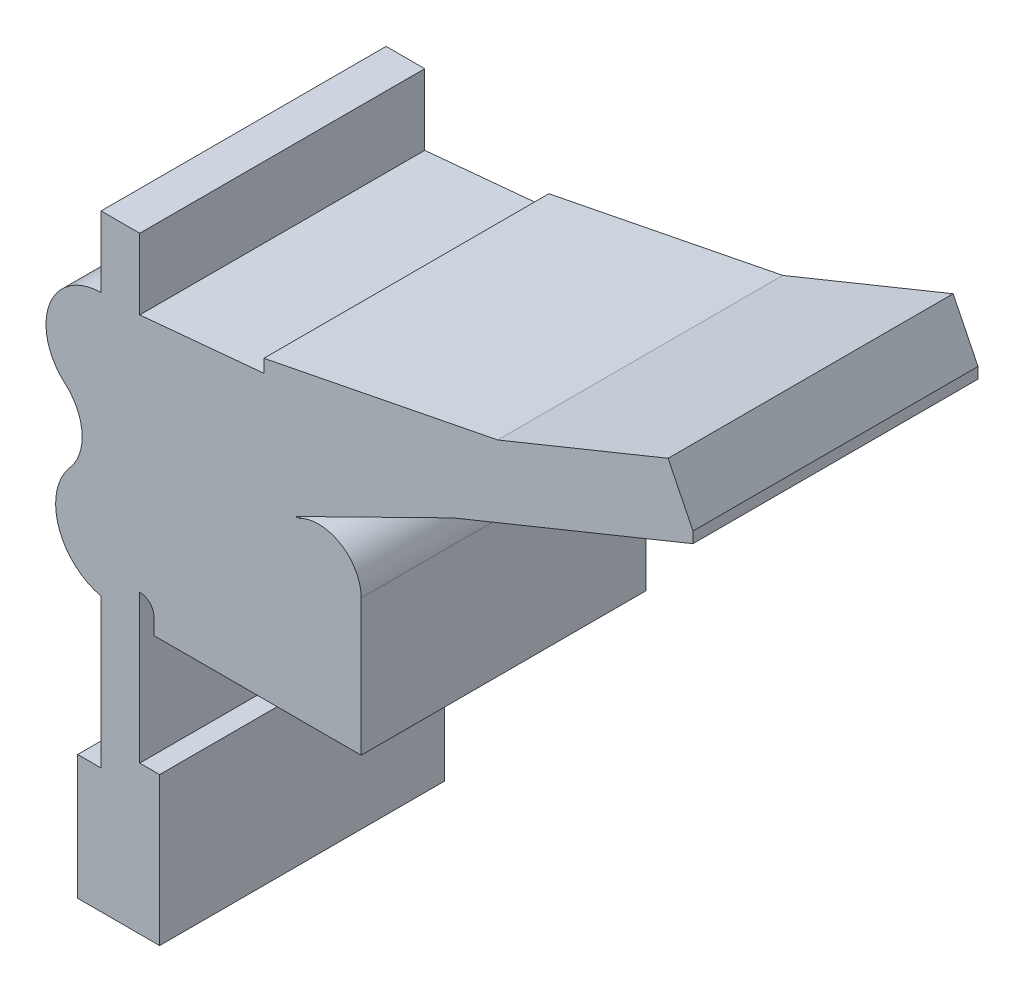
from build123d import *

# Parameters (mm, degrees)
BOSS_EXTRUDE1_DEPTH = 59


with BuildPart() as part:
    # Sketch1 → Boss-Extrude1 (new body)
    with BuildSketch(Plane.XY):
        with BuildLine():
            Line((141.836213574, 162.11895664), (136.686788287, 172.578726755))
            Line((136.686788287, 172.578726755), (101.422420471, 158.233899169))
            Line((101.422420471, 158.233899169), (53.008627367, 148.670680778))
            Line((53.008627367, 148.670680778), (53.008627367, 145.981025606))
            Line((53.008627367, 145.981025606), (27.307477942, 143.590221008))
            Line((27.307477942, 143.590221008), (27.307477942, 158.233899169))
            Line((27.307477942, 158.233899169), (19.307477942, 158.233899169))
            Line((19.307477942, 158.233899169), (19.307477942, 143.590221008))
            ThreePointArc((19.307477942, 143.590221008), (8.621741422, 136.172049269), (11.836213574, 123.567232502))
            ThreePointArc((11.836213574, 123.567232502), (15.367024557, 116.508815615), (12.8726305, 109.02110078))
            ThreePointArc((12.8726305, 109.02110078), (10.487522097, 97.279293257), (19.307477942, 89.169597523))
            Line((19.307477942, 89.169597523), (19.307477942, 58.363836225))
            Line((19.307477942, 58.363836225), (14.461757095, 58.363836225))
            Line((14.461757095, 58.363836225), (14.461757095, 32.578726755))
            Line((14.461757095, 32.578726755), (31.423101088, 32.578726755))
            Line((31.423101088, 32.578726755), (31.423101088, 63.242577829))
            Line((31.423101088, 63.242577829), (27.307477942, 63.242577829))
            Line((27.307477942, 63.242577829), (27.307477942, 93.887357851))
            ThreePointArc((27.307477942, 93.887357851), (29.389559507, 93.024931429), (30.251985929, 90.942849864))
            Line((30.251985929, 90.942849864), (30.251985929, 87.578726755))
            Line((30.251985929, 87.578726755), (73.151157521, 87.578726755))
            Line((73.151157521, 87.578726755), (73.151157521, 91.578726755))
            Line((73.151157521, 91.578726755), (73.151157521, 115.775958178))
            ThreePointArc((73.151157521, 115.775958178), (68.856721822, 123.355383827), (60.147818832, 123.567232502))
            Line((60.147818832, 123.567232502), (59.530992057, 123.567232502))
            Line((59.530992057, 123.567232502), (92.194583693, 139.647769923))
            Line((92.194583693, 139.647769923), (141.836213574, 159.840975298))
            Line((141.836213574, 159.840975298), (141.836213574, 162.11895664))
        make_face()
    extrude(amount=BOSS_EXTRUDE1_DEPTH)


solid = part.part
